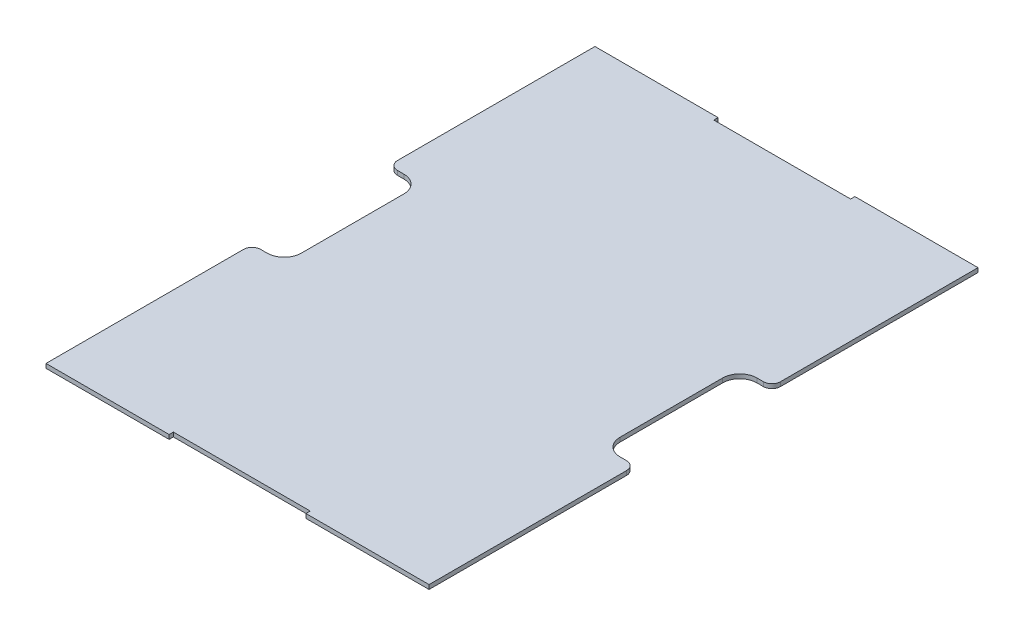
from build123d import *

# Parameters (mm, degrees)
BOSS_EXTRUDE1_DEPTH = 0.79375
FILLET2_R           = 6.35
FILLET3_R           = 3.175


with BuildPart() as part:
    # Sketch1 → Boss-Extrude1 (new body, symmetric)
    with BuildSketch(Plane(origin=(0, 0, 0), x_dir=(1, 0, 0), z_dir=(0, 1, 0))):
        Polygon((-71.12, 101.9175), (-25.4, 101.9175), (-25.4, 100.33), (25.4, 100.33), (25.4, 101.9175), (71.12, 101.9175), (71.12, 25.4), (59.182, 25.4), (59.182, -25.4), (71.12, -25.4), (71.12, -101.9175), (25.4, -101.9175), (25.4, -100.33), (-25.4, -100.33), (-25.4, -101.9175), (-71.12, -101.9175), (-71.12, -25.4), (-59.182, -25.4), (-59.182, 25.4), (-71.12, 25.4), align=None)
    extrude(amount=BOSS_EXTRUDE1_DEPTH, both=True)

    # Fillet2
    fillet2_edges = [part.edges().sort_by_distance(p)[0] for p in [
        (59.182, 0, -25.4),
        (59.182, 0, 25.4),
        (-59.182, 0, 25.4),
        (-59.182, 0, -25.4),
    ]]
    fillet(fillet2_edges, radius=FILLET2_R)

    # Fillet3
    fillet3_edges = [part.edges().sort_by_distance(p)[0] for p in [
        (71.12, 0, -25.4),
        (71.12, 0, 25.4),
        (-71.12, 0, 25.4),
        (-71.12, 0, -25.4),
    ]]
    fillet(fillet3_edges, radius=FILLET3_R)


solid = part.part
